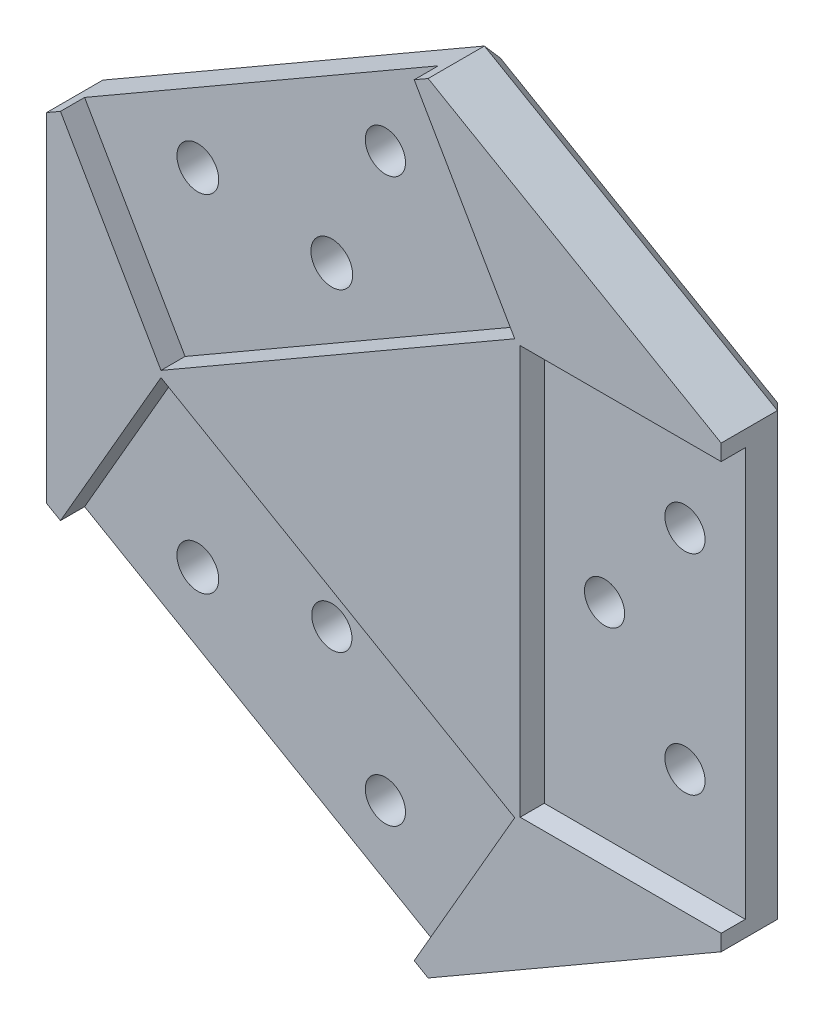
from build123d import *

# Parameters (mm, degrees)
SKETCH1_R           = 2.5
SKETCH1_R_2         = 2.6
BOSS_EXTRUDE1_DEPTH = 6
BOSS_EXTRUDE2_DEPTH = 3
CHAMFER1_SIZE       = 2


with BuildPart() as part:
    # Sketch1 → Boss-Extrude1 (new body)
    with BuildSketch(Plane.XY):
        Polygon((2998.461039771, 1261.470901479), (2998.461039771, 1206.670901479), (2962.016271034, 1185.629504438), (2914.558078907, 1213.029504438), (2914.558078907, 1255.11229852), (2962.016271034, 1282.51229852), align=None)
        with Locations((2990.961039771, 1221.070901479)):
            Circle(SKETCH1_R, mode=Mode.SUBTRACT)
        with Locations((2980.961039771, 1234.070901479)):
            Circle(SKETCH1_R, mode=Mode.SUBTRACT)
        with Locations((2990.961039771, 1247.070901479)):
            Circle(SKETCH1_R, mode=Mode.SUBTRACT)
        with Locations((2953.699650408, 1269.050441325)):
            Circle(SKETCH1_R, mode=Mode.SUBTRACT)
        with Locations((2930.374699533, 1255.583774658)):
            Circle(SKETCH1_R_2, mode=Mode.SUBTRACT)
        with Locations((2947.03717497, 1214.484949004)):
            Circle(SKETCH1_R, mode=Mode.SUBTRACT)
        with Locations((2953.699650408, 1199.091361633)):
            Circle(SKETCH1_R, mode=Mode.SUBTRACT)
        with Locations((2930.374699533, 1212.5580283)):
            Circle(SKETCH1_R_2, mode=Mode.SUBTRACT)
        with Locations((2947.03717497, 1253.656853954)):
            Circle(SKETCH1_R_2, mode=Mode.SUBTRACT)
    extrude(amount=BOSS_EXTRUDE1_DEPTH)

    # Sketch2 → Boss-Extrude2 (add)
    with BuildSketch(Plane.XY.offset(6)):
        Polygon((2916.290129714, 1212.029504438), (2928.790129714, 1233.680139532), (2972.784220226, 1208.280139532), (2960.284220226, 1186.629504438), (2962.016271034, 1185.629504438), (2998.461039771, 1206.670901479), (2998.461039771, 1208.670901479), (2973.461039771, 1208.670901479), (2973.461039771, 1259.470901479), (2998.461039771, 1259.470901479), (2998.461039771, 1261.470901479), (2962.016271034, 1282.51229852), (2960.284220226, 1281.51229852), (2972.784220226, 1259.861663425), (2928.790129714, 1234.461663425), (2916.290129714, 1256.11229852), (2914.558078907, 1255.11229852), (2914.558078907, 1213.029504438), align=None)
    extrude(amount=BOSS_EXTRUDE2_DEPTH)

    # Chamfer1
    chamfer1_edges = [part.edges().sort_by_distance(p)[0] for p in [
        (2980.238655403, 1196.150202958, 0),
        (2938.28717497, 1199.329504438, 0),
        (2914.558078907, 1234.070901479, 0),
        (2938.28717497, 1268.81229852, 0),
        (2980.238655403, 1271.991599999, 0),
        (2998.461039771, 1234.070901479, 0),
    ]]
    chamfer(chamfer1_edges, length=CHAMFER1_SIZE)


solid = part.part
